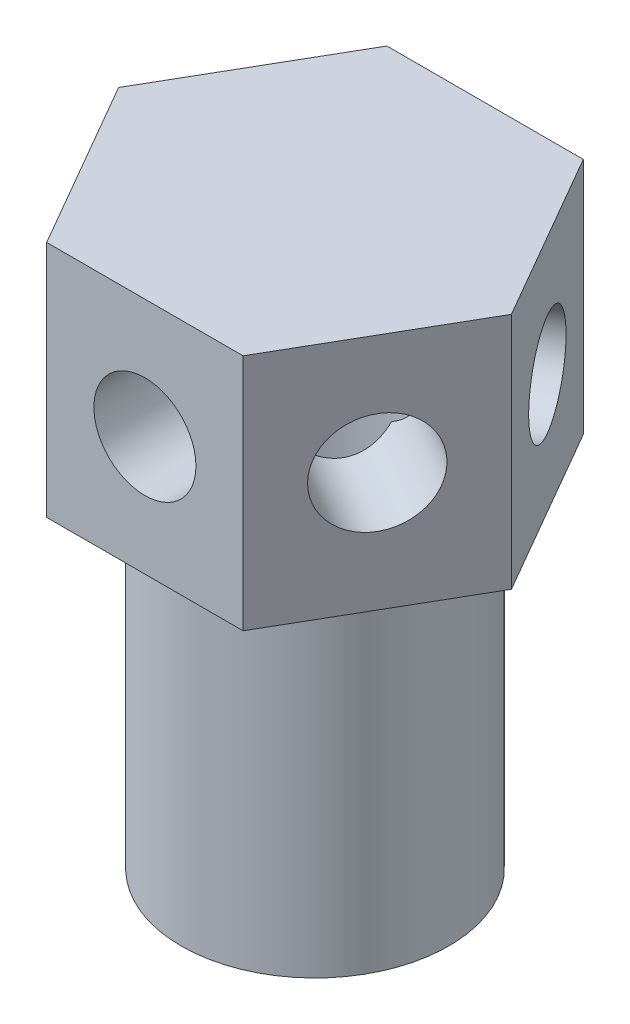
from build123d import *

# Parameters (mm, degrees)
AUFSATZ_LINEAR_AUSTRAGEN1_DEPTH = 17
SKIZZE2_R                       = 6.935
SKIZZE2_R_2                     = 3.935
SCHNITT_LINEAR_AUSTRAGEN1_DEPTH = 10
SKIZZE3_R                       = 2.25
SCHNITT_LINEAR_AUSTRAGEN2_DEPTH = 15
SKIZZE4_R                       = 1.5
SCHNITT_LINEAR_AUSTRAGEN3_DEPTH = 13.5
KREISMUSTER1_COUNT              = 3
KREISMUSTER1_ANGLE              = 240


with BuildPart() as part:
    # Skizze1 → Aufsatz-Linear austragen1 (new body)
    with BuildSketch(Plane(origin=(0, 0, 0), x_dir=(1, 0, 0), z_dir=(0, 1, 0))):
        Polygon((2.886751346, -5), (5.773502692, 0), (2.886751346, 5), (-2.886751346, 5), (-5.773502692, 0), (-2.886751346, -5), align=None)
    extrude(amount=AUFSATZ_LINEAR_AUSTRAGEN1_DEPTH)

    # Skizze2 → Schnitt-Linear austragen1 (cut)
    with BuildSketch(Plane.XZ):
        Circle(SKIZZE2_R)
        Circle(SKIZZE2_R_2, mode=Mode.SUBTRACT)
    extrude(amount=-SCHNITT_LINEAR_AUSTRAGEN1_DEPTH, mode=Mode.SUBTRACT)

    # Skizze3 → Schnitt-Linear austragen2 (cut)
    with BuildSketch(Plane.XZ):
        Circle(SKIZZE3_R)
    extrude(amount=-SCHNITT_LINEAR_AUSTRAGEN2_DEPTH, mode=Mode.SUBTRACT)

    # Skizze4 → Schnitt-Linear austragen3 (cut, through all)
    with BuildSketch(Plane(origin=(4.330127019, 0, -2.5), x_dir=(-0.5, 0, -0.866025404), z_dir=(0.866025404, 0, -0.5))):
        with Locations((0, 13.5)):
            Circle(SKIZZE4_R)
    schnitt_linear_austragen3 = extrude(amount=-SCHNITT_LINEAR_AUSTRAGEN3_DEPTH, mode=Mode.SUBTRACT)

    # Kreismuster1: Schnitt-Linear austragen3 ×3 about axis
    kreismuster1_axis = Axis((0, 0, 0), (0, -1, 0))
    for i in range(1, KREISMUSTER1_COUNT):
        add(schnitt_linear_austragen3.rotate(kreismuster1_axis, i * KREISMUSTER1_ANGLE / (KREISMUSTER1_COUNT - 1)), mode=Mode.SUBTRACT)


solid = part.part
